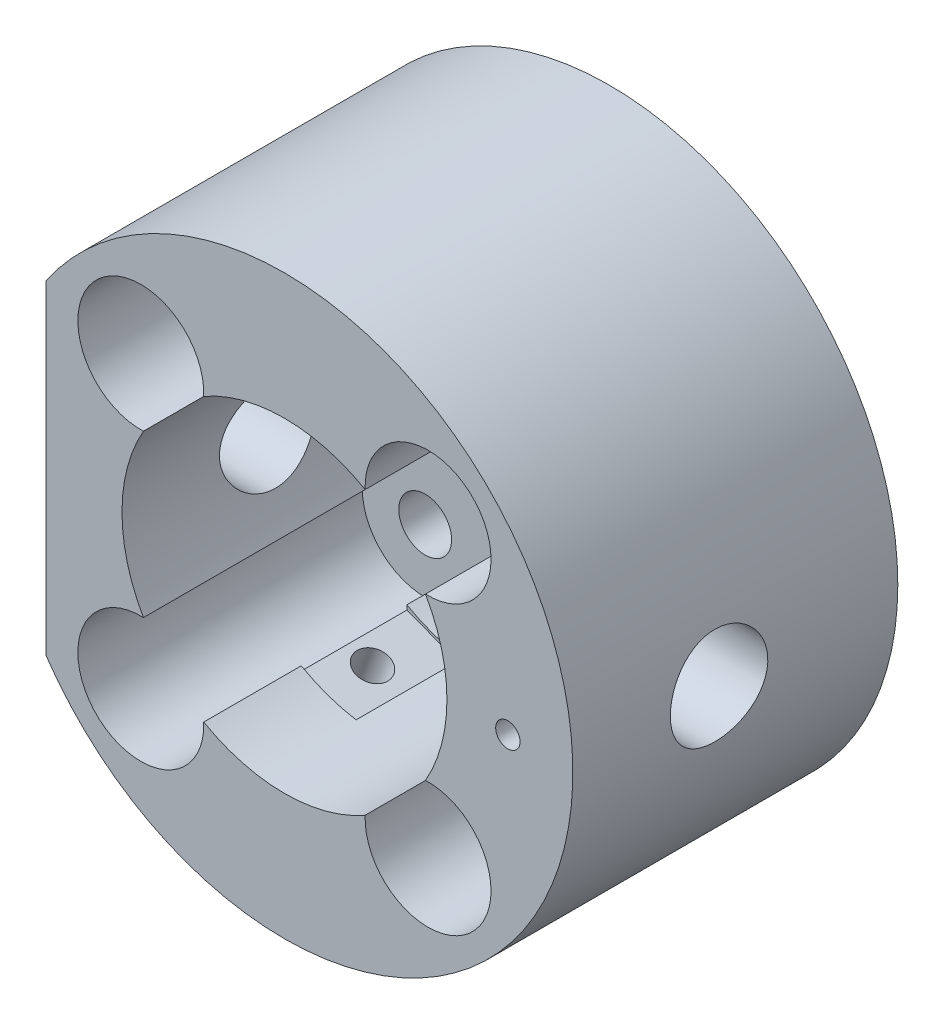
from build123d import *

# Parameters (mm, degrees)
CROQUIS1_R                   = 35.5
CROQUIS1_R_2                 = 3.25
SALIENTE_EXTRUIR1_DEPTH      = 5
SALIENTE_EXTRUIR2_DEPTH      = 35
CROQUIS3_R                   = 6
CORTAR_EXTRUIR1_DEPTH        = 65.830018752
CORTAR_EXTRUIR2_REACH        = 42
CROQUIS4_R                   = 1.5
CORTAR_EXTRUIR_L_MINA1_START = 11
CORTAR_EXTRUIR_L_MINA1_DEPTH = 13
CORTAR_EXTRUIR3_REACH        = 83.025
CROQUIS6_R                   = 2
CORTAR_EXTRUIR_L_MINA2_START = 10
CORTAR_EXTRUIR_L_MINA2_DEPTH = 13


with BuildPart() as part:
    # Croquis1 → Saliente-Extruir1 (new body)
    with BuildSketch(Plane.XY):
        Circle(CROQUIS1_R)
        with Locations((17.67766953, 17.67766953)):
            Circle(CROQUIS1_R_2, mode=Mode.SUBTRACT)
        with Locations((17.67766953, -17.67766953)):
            Circle(CROQUIS1_R_2, mode=Mode.SUBTRACT)
        with Locations((-17.67766953, -17.67766953)):
            Circle(CROQUIS1_R_2, mode=Mode.SUBTRACT)
        with Locations((-17.67766953, 17.67766953)):
            Circle(CROQUIS1_R_2, mode=Mode.SUBTRACT)
        Circle(CROQUIS1_R_2, mode=Mode.SUBTRACT)
    extrude(amount=SALIENTE_EXTRUIR1_DEPTH)

    # Croquis2 → Saliente-Extruir2 (add)
    with BuildSketch(Plane.XY.offset(5)):
        with BuildLine():
            ThreePointArc((-29.330018752, -20), (35.5, 0), (-29.330018752, 20))
            Line((-29.330018752, 20), (-29.330018752, -20))
        make_face()
        with BuildLine():
            ThreePointArc((-9.934252718, 17.358301269), (0, 20), (9.934252718, 17.358301268))
            ThreePointArc((9.934252718, 17.358301268), (23.157747084, 23.157747084), (17.358301268, 9.934252718))
            ThreePointArc((17.358301268, 9.934252718), (20, 0), (17.358301268, -9.934252718))
            ThreePointArc((17.358301268, -9.934252718), (23.157747084, -23.157747084), (9.934252718, -17.358301268))
            ThreePointArc((9.934252718, -17.358301268), (0, -20), (-9.934252718, -17.358301268))
            ThreePointArc((-9.934252718, -17.358301268), (-23.157747084, -23.157747084), (-17.358301268, -9.934252718))
            ThreePointArc((-17.358301268, -9.934252718), (-20, 0), (-17.358301269, 9.934252718))
            ThreePointArc((-17.358301269, 9.934252718), (-23.157747084, 23.157747084), (-9.934252718, 17.358301268))
        make_face(mode=Mode.SUBTRACT)
    extrude(amount=SALIENTE_EXTRUIR2_DEPTH)

    # Croquis3 → Cortar-Extruir1 (cut, through all)
    with BuildSketch(Plane.ZY.offset(29.330018752)):
        with Locations((22, 0)):
            Circle(CROQUIS3_R)
    extrude(amount=-CORTAR_EXTRUIR1_DEPTH, mode=Mode.SUBTRACT)

    # Croquis4 → Cortar-Extruir2 (cut, up to next)
    with BuildSketch(Plane.XY.offset(40), mode=Mode.PRIVATE) as cortar_extruir2_sk1:
        with Locations((27.5, 0)):
            Circle(CROQUIS4_R)
    cortar_extruir2_tool1 = extrude(cortar_extruir2_sk1.sketch, amount=-CORTAR_EXTRUIR2_REACH, mode=Mode.PRIVATE) & part.part
    add(cortar_extruir2_tool1.solids().sort_by_distance((27.5, 0, 40))[0], mode=Mode.SUBTRACT)

    # Croquis5 → Cortar-Extruir-L_mina1 (cut)
    with BuildSketch(Plane.XY.offset(5).offset(CORTAR_EXTRUIR_L_MINA1_START)):
        Polygon((-16.202076443, -31.58706569), (-8.717795145, -34.41293431), (-9.4242623, -36.284004634), (-16.908543598, -33.458136015), align=None)
    extrude(amount=CORTAR_EXTRUIR_L_MINA1_DEPTH, mode=Mode.SUBTRACT)

    # Croquis6 → Cortar-Extruir3 (cut, up to next)
    with BuildSketch(Plane(origin=(-12.459935794, -33, 0), x_dir=(0.935535162, -0.353233577, 0), z_dir=(-0.353233577, -0.935535162, 0)), mode=Mode.PRIVATE) as cortar_extruir3_sk1:
        with Locations((0, 22)):
            Circle(CROQUIS6_R)
    cortar_extruir3_tool1 = extrude(cortar_extruir3_sk1.sketch, amount=-CORTAR_EXTRUIR3_REACH, mode=Mode.PRIVATE) & part.part
    add(cortar_extruir3_tool1.solids().sort_by_distance((-12.459936, -33, 22))[0], mode=Mode.SUBTRACT)

    # Croquis7 → Cortar-Extruir-L_mina2 (cut)
    with BuildSketch(Plane.XY.offset(5).offset(CORTAR_EXTRUIR_L_MINA2_START)):
        Polygon((-10.903572782, -17.554038257), (-3.419291484, -20.379906876), (-2.712824329, -18.508836552), (-10.197105627, -15.682967932), align=None)
    extrude(amount=CORTAR_EXTRUIR_L_MINA2_DEPTH, mode=Mode.SUBTRACT)


solid = part.part
